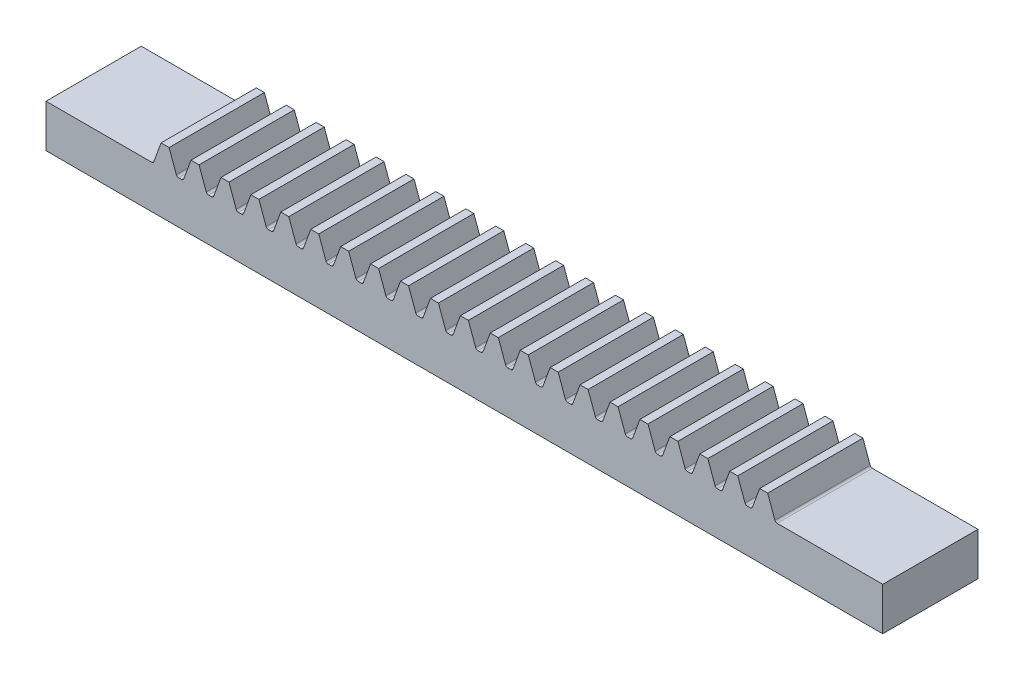
from build123d import *

# Parameters (mm, degrees)
SKETCH1_W              = 155.663706144
SKETCH1_H              = 4
BOSS_EXTRUDE1_DEPTH    = 10
BOSS_EXTRUDE4_DEPTH    = 10
FILLET1_R              = 0.5
LPATTERN1_COUNT        = 21
LPATTERN1_PITCH        = 6.283185307
FILLET1_OF_LPATTERN1_R = 0.5
BOSS_EXTRUDE6_DEPTH    = 6
SKETCH11_W             = 16
SKETCH11_H             = 4
BOSS_EXTRUDE8_DEPTH    = 10
SKETCH12_W             = 16
SKETCH12_H             = 4
BOSS_EXTRUDE9_DEPTH    = 10
SKETCH15_W             = 175.663706144
SKETCH15_H             = 16
BOSS_EXTRUDE10_DEPTH   = 5
BOSS_EXTRUDE11_DEPTH   = 4


with BuildPart() as part:
    # Sketch1 → Boss-Extrude1 (new body)
    with BuildSketch(Plane.XY):
        with Locations((0, 2)):
            Rectangle(SKETCH1_W, SKETCH1_H)
    extrude(amount=BOSS_EXTRUDE1_DEPTH)

    # Sketch2 → Boss-Extrude4 (add)
    with BuildSketch(Plane.XY):
        Polygon((-65.312574984, 4), (-63.67470893, 8.5), (-61.988997214, 8.5), (-60.351131159, 4), align=None)
    boss_extrude4 = extrude(amount=BOSS_EXTRUDE4_DEPTH)

    # Fillet1
    fillet1_edges = [part.edges().sort_by_distance(p)[0] for p in [
        (-60.351131159, 4, 5),
        (-65.312574984, 4, 5),
    ]]
    fillet(fillet1_edges, radius=FILLET1_R)

    # LPattern1: Boss-Extrude4 ×21
    with Locations(*[(i * LPATTERN1_PITCH, 0, 0) for i in range(1, LPATTERN1_COUNT)]):
        add(boss_extrude4)

    # Fillet1 of LPattern1
    fillet1_of_lpattern1_edges = [part.edges().sort_by_distance(p)[0] for p in [
        (-54.067945852, 4, 5),
        (-59.029389677, 4, 5),
        (-47.784760545, 4, 5),
        (-52.74620437, 4, 5),
        (-41.501575238, 4, 5),
        (-46.463019063, 4, 5),
        (-35.218389931, 4, 5),
        (-40.179833756, 4, 5),
        (-28.935204623, 4, 5),
        (-33.896648448, 4, 5),
        (-22.652019316, 4, 5),
        (-27.613463141, 4, 5),
        (-16.368834009, 4, 5),
        (-21.330277834, 4, 5),
        (-10.085648702, 4, 5),
        (-15.047092527, 4, 5),
        (-3.802463395, 4, 5),
        (-8.76390722, 4, 5),
        (2.480721912, 4, 5),
        (-2.480721912, 4, 5),
        (8.76390722, 4, 5),
        (3.802463395, 4, 5),
        (15.047092527, 4, 5),
        (10.085648702, 4, 5),
        (21.330277834, 4, 5),
        (16.368834009, 4, 5),
        (27.613463141, 4, 5),
        (22.652019316, 4, 5),
        (33.896648448, 4, 5),
        (28.935204623, 4, 5),
        (40.179833756, 4, 5),
        (35.218389931, 4, 5),
        (46.463019063, 4, 5),
        (41.501575238, 4, 5),
        (52.74620437, 4, 5),
        (47.784760545, 4, 5),
        (59.029389677, 4, 5),
        (54.067945852, 4, 5),
        (65.312574984, 4, 5),
        (60.351131159, 4, 5),
    ]]
    fillet(fillet1_of_lpattern1_edges, radius=FILLET1_OF_LPATTERN1_R)

    # Sketch9 → Boss-Extrude6 (add)
    with BuildSketch(Plane.XY.offset(10)):
        with BuildLine():
            Line((-77.831853072, 4), (-77.831853072, 0))
            Line((-77.831853072, 0), (77.831853072, 0))
            Line((77.831853072, 0), (77.831853072, 4))
            Line((77.831853072, 4), (65.662678753, 4))
            ThreePointArc((65.662678753, 4), (65.375890535, 4.090423978), (65.192832443, 4.328989928))
            Line((65.192832443, 4.328989928), (63.67470893, 8.5))
            Line((63.67470893, 8.5), (61.988997214, 8.5))
            Line((61.988997214, 8.5), (60.470873701, 4.328989928))
            ThreePointArc((60.470873701, 4.328989928), (60.287815608, 4.090423978), (60.00102739, 4))
            Line((60.00102739, 4), (59.379493446, 4))
            ThreePointArc((59.379493446, 4), (59.092705228, 4.090423978), (58.909647136, 4.328989928))
            Line((58.909647136, 4.328989928), (57.391523623, 8.5))
            Line((57.391523623, 8.5), (55.705811906, 8.5))
            Line((55.705811906, 8.5), (54.187688393, 4.328989928))
            ThreePointArc((54.187688393, 4.328989928), (54.004630301, 4.090423978), (53.717842083, 4))
            Line((53.717842083, 4), (53.096308139, 4))
            ThreePointArc((53.096308139, 4), (52.809519921, 4.090423978), (52.626461829, 4.328989928))
            Line((52.626461829, 4.328989928), (51.108338316, 8.5))
            Line((51.108338316, 8.5), (49.422626599, 8.5))
            Line((49.422626599, 8.5), (47.904503086, 4.328989928))
            ThreePointArc((47.904503086, 4.328989928), (47.721444994, 4.090423978), (47.434656776, 4))
            Line((47.434656776, 4), (46.813122832, 4))
            ThreePointArc((46.813122832, 4), (46.526334614, 4.090423978), (46.343276521, 4.328989928))
            Line((46.343276521, 4.328989928), (44.825153009, 8.5))
            Line((44.825153009, 8.5), (43.139441292, 8.5))
            Line((43.139441292, 8.5), (41.621317779, 4.328989928))
            ThreePointArc((41.621317779, 4.328989928), (41.438259687, 4.090423978), (41.151471469, 4))
            Line((41.151471469, 4), (40.529937525, 4))
            ThreePointArc((40.529937525, 4), (40.243149306, 4.090423978), (40.060091214, 4.328989928))
            Line((40.060091214, 4.328989928), (38.541967701, 8.5))
            Line((38.541967701, 8.5), (36.856255985, 8.5))
            Line((36.856255985, 8.5), (35.338132472, 4.328989928))
            ThreePointArc((35.338132472, 4.328989928), (35.15507438, 4.090423978), (34.868286162, 4))
            Line((34.868286162, 4), (34.246752217, 4))
            ThreePointArc((34.246752217, 4), (33.959963999, 4.090423978), (33.776905907, 4.328989928))
            Line((33.776905907, 4.328989928), (32.258782394, 8.5))
            Line((32.258782394, 8.5), (30.573070678, 8.5))
            Line((30.573070678, 8.5), (29.054947165, 4.328989928))
            ThreePointArc((29.054947165, 4.328989928), (28.871889073, 4.090423978), (28.585100854, 4))
            Line((28.585100854, 4), (27.96356691, 4))
            ThreePointArc((27.96356691, 4), (27.676778692, 4.090423978), (27.4937206, 4.328989928))
            Line((27.4937206, 4.328989928), (25.975597087, 8.5))
            Line((25.975597087, 8.5), (24.28988537, 8.5))
            Line((24.28988537, 8.5), (22.771761858, 4.328989928))
            ThreePointArc((22.771761858, 4.328989928), (22.588703765, 4.090423978), (22.301915547, 4))
            Line((22.301915547, 4), (21.680381603, 4))
            ThreePointArc((21.680381603, 4), (21.393593385, 4.090423978), (21.210535293, 4.328989928))
            Line((21.210535293, 4.328989928), (19.69241178, 8.5))
            Line((19.69241178, 8.5), (18.006700063, 8.5))
            Line((18.006700063, 8.5), (16.48857655, 4.328989928))
            ThreePointArc((16.48857655, 4.328989928), (16.305518458, 4.090423978), (16.01873024, 4))
            Line((16.01873024, 4), (15.397196296, 4))
            ThreePointArc((15.397196296, 4), (15.110408078, 4.090423978), (14.927349986, 4.328989928))
            Line((14.927349986, 4.328989928), (13.409226473, 8.5))
            Line((13.409226473, 8.5), (11.723514756, 8.5))
            Line((11.723514756, 8.5), (10.205391243, 4.328989928))
            ThreePointArc((10.205391243, 4.328989928), (10.022333151, 4.090423978), (9.735544933, 4))
            Line((9.735544933, 4), (9.114010989, 4))
            ThreePointArc((9.114010989, 4), (8.827222771, 4.090423978), (8.644164678, 4.328989928))
            Line((8.644164678, 4.328989928), (7.126041165, 8.5))
            Line((7.126041165, 8.5), (5.440329449, 8.5))
            Line((5.440329449, 8.5), (3.922205936, 4.328989928))
            ThreePointArc((3.922205936, 4.328989928), (3.739147844, 4.090423978), (3.452359626, 4))
            Line((3.452359626, 4), (2.830825682, 4))
            ThreePointArc((2.830825682, 4), (2.544037463, 4.090423978), (2.360979371, 4.328989928))
            Line((2.360979371, 4.328989928), (0.842855858, 8.5))
            Line((0.842855858, 8.5), (-0.842855858, 8.5))
            Line((-0.842855858, 8.5), (-2.360979371, 4.328989928))
            ThreePointArc((-2.360979371, 4.328989928), (-2.544037463, 4.090423978), (-2.830825682, 4))
            Line((-2.830825682, 4), (-3.452359626, 4))
            ThreePointArc((-3.452359626, 4), (-3.739147844, 4.090423978), (-3.922205936, 4.328989928))
            Line((-3.922205936, 4.328989928), (-5.440329449, 8.5))
            Line((-5.440329449, 8.5), (-7.126041165, 8.5))
            Line((-7.126041165, 8.5), (-8.644164678, 4.328989928))
            ThreePointArc((-8.644164678, 4.328989928), (-8.827222771, 4.090423978), (-9.114010989, 4))
            Line((-9.114010989, 4), (-9.735544933, 4))
            ThreePointArc((-9.735544933, 4), (-10.022333151, 4.090423978), (-10.205391243, 4.328989928))
            Line((-10.205391243, 4.328989928), (-11.723514756, 8.5))
            Line((-11.723514756, 8.5), (-13.409226473, 8.5))
            Line((-13.409226473, 8.5), (-14.927349986, 4.328989928))
            ThreePointArc((-14.927349986, 4.328989928), (-15.110408078, 4.090423978), (-15.397196296, 4))
            Line((-15.397196296, 4), (-16.01873024, 4))
            ThreePointArc((-16.01873024, 4), (-16.305518458, 4.090423978), (-16.48857655, 4.328989928))
            Line((-16.48857655, 4.328989928), (-18.006700063, 8.5))
            Line((-18.006700063, 8.5), (-19.69241178, 8.5))
            Line((-19.69241178, 8.5), (-21.210535293, 4.328989928))
            ThreePointArc((-21.210535293, 4.328989928), (-21.393593385, 4.090423978), (-21.680381603, 4))
            Line((-21.680381603, 4), (-22.301915547, 4))
            ThreePointArc((-22.301915547, 4), (-22.588703765, 4.090423978), (-22.771761858, 4.328989928))
            Line((-22.771761858, 4.328989928), (-24.28988537, 8.5))
            Line((-24.28988537, 8.5), (-25.975597087, 8.5))
            Line((-25.975597087, 8.5), (-27.4937206, 4.328989928))
            ThreePointArc((-27.4937206, 4.328989928), (-27.676778692, 4.090423978), (-27.96356691, 4))
            Line((-27.96356691, 4), (-28.585100854, 4))
            ThreePointArc((-28.585100854, 4), (-28.871889073, 4.090423978), (-29.054947165, 4.328989928))
            Line((-29.054947165, 4.328989928), (-30.573070678, 8.5))
            Line((-30.573070678, 8.5), (-32.258782394, 8.5))
            Line((-32.258782394, 8.5), (-33.776905907, 4.328989928))
            ThreePointArc((-33.776905907, 4.328989928), (-33.959963999, 4.090423978), (-34.246752217, 4))
            Line((-34.246752217, 4), (-34.868286162, 4))
            ThreePointArc((-34.868286162, 4), (-35.15507438, 4.090423978), (-35.338132472, 4.328989928))
            Line((-35.338132472, 4.328989928), (-36.856255985, 8.5))
            Line((-36.856255985, 8.5), (-38.541967701, 8.5))
            Line((-38.541967701, 8.5), (-40.060091214, 4.328989928))
            ThreePointArc((-40.060091214, 4.328989928), (-40.243149306, 4.090423978), (-40.529937525, 4))
            Line((-40.529937525, 4), (-41.151471469, 4))
            ThreePointArc((-41.151471469, 4), (-41.438259687, 4.090423978), (-41.621317779, 4.328989928))
            Line((-41.621317779, 4.328989928), (-43.139441292, 8.5))
            Line((-43.139441292, 8.5), (-44.825153009, 8.5))
            Line((-44.825153009, 8.5), (-46.343276521, 4.328989928))
            ThreePointArc((-46.343276521, 4.328989928), (-46.526334614, 4.090423978), (-46.813122832, 4))
            Line((-46.813122832, 4), (-47.434656776, 4))
            ThreePointArc((-47.434656776, 4), (-47.721444994, 4.090423978), (-47.904503086, 4.328989928))
            Line((-47.904503086, 4.328989928), (-49.422626599, 8.5))
            Line((-49.422626599, 8.5), (-51.108338316, 8.5))
            Line((-51.108338316, 8.5), (-52.626461829, 4.328989928))
            ThreePointArc((-52.626461829, 4.328989928), (-52.809519921, 4.090423978), (-53.096308139, 4))
            Line((-53.096308139, 4), (-53.717842083, 4))
            ThreePointArc((-53.717842083, 4), (-54.004630301, 4.090423978), (-54.187688393, 4.328989928))
            Line((-54.187688393, 4.328989928), (-55.705811906, 8.5))
            Line((-55.705811906, 8.5), (-57.391523623, 8.5))
            Line((-57.391523623, 8.5), (-58.909647136, 4.328989928))
            ThreePointArc((-58.909647136, 4.328989928), (-59.092705228, 4.090423978), (-59.379493446, 4))
            Line((-59.379493446, 4), (-60.00102739, 4))
            ThreePointArc((-60.00102739, 4), (-60.287815608, 4.090423978), (-60.470873701, 4.328989928))
            Line((-60.470873701, 4.328989928), (-61.988997214, 8.5))
            Line((-61.988997214, 8.5), (-63.67470893, 8.5))
            Line((-63.67470893, 8.5), (-65.192832443, 4.328989928))
            ThreePointArc((-65.192832443, 4.328989928), (-65.375890535, 4.090423978), (-65.662678753, 4))
            Line((-65.662678753, 4), (-77.831853072, 4))
        make_face()
    extrude(amount=BOSS_EXTRUDE6_DEPTH)

    # Sketch11 → Boss-Extrude8 (add)
    with BuildSketch(Plane.ZY.offset(77.831853072)):
        with Locations((8, 2)):
            Rectangle(SKETCH11_W, SKETCH11_H)
    extrude(amount=BOSS_EXTRUDE8_DEPTH)

    # Sketch12 → Boss-Extrude9 (add)
    with BuildSketch(Plane(origin=(77.831853072, 0, 0), x_dir=(0, 0, -1), z_dir=(1, 0, 0))):
        with Locations((-8, 2)):
            Rectangle(SKETCH12_W, SKETCH12_H)
    extrude(amount=BOSS_EXTRUDE9_DEPTH)

    # Sketch15 → Boss-Extrude10 (add)
    with BuildSketch(Plane.XZ):
        with Locations((0, 8)):
            Rectangle(SKETCH15_W, SKETCH15_H)
    extrude(amount=BOSS_EXTRUDE10_DEPTH)

    # Sketch16 → Boss-Extrude11 (add)
    with BuildSketch(Plane.XY.offset(16)):
        with BuildLine():
            Line((-61.988997214, 8.5), (-63.67470893, 8.5))
            Line((-63.67470893, 8.5), (-65.192832443, 4.328989928))
            ThreePointArc((-65.192832443, 4.328989928), (-65.375890535, 4.090423978), (-65.662678753, 4))
            Line((-65.662678753, 4), (-87.831853072, 4))
            Line((-87.831853072, 4), (-87.831853072, -5))
            Line((-87.831853072, -5), (87.831853072, -5))
            Line((87.831853072, -5), (87.831853072, 4))
            Line((87.831853072, 4), (65.662678753, 4))
            ThreePointArc((65.662678753, 4), (65.375890535, 4.090423978), (65.192832443, 4.328989928))
            Line((65.192832443, 4.328989928), (63.67470893, 8.5))
            Line((63.67470893, 8.5), (61.988997214, 8.5))
            Line((61.988997214, 8.5), (60.470873701, 4.328989928))
            ThreePointArc((60.470873701, 4.328989928), (60.287815608, 4.090423978), (60.00102739, 4))
            Line((60.00102739, 4), (59.379493446, 4))
            ThreePointArc((59.379493446, 4), (59.092705228, 4.090423978), (58.909647136, 4.328989928))
            Line((58.909647136, 4.328989928), (57.391523623, 8.5))
            Line((57.391523623, 8.5), (55.705811906, 8.5))
            Line((55.705811906, 8.5), (54.187688393, 4.328989928))
            ThreePointArc((54.187688393, 4.328989928), (54.004630301, 4.090423978), (53.717842083, 4))
            Line((53.717842083, 4), (53.096308139, 4))
            ThreePointArc((53.096308139, 4), (52.809519921, 4.090423978), (52.626461829, 4.328989928))
            Line((52.626461829, 4.328989928), (51.108338316, 8.5))
            Line((51.108338316, 8.5), (49.422626599, 8.5))
            Line((49.422626599, 8.5), (47.904503086, 4.328989928))
            ThreePointArc((47.904503086, 4.328989928), (47.721444994, 4.090423978), (47.434656776, 4))
            Line((47.434656776, 4), (46.813122832, 4))
            ThreePointArc((46.813122832, 4), (46.526334614, 4.090423978), (46.343276521, 4.328989928))
            Line((46.343276521, 4.328989928), (44.825153009, 8.5))
            Line((44.825153009, 8.5), (43.139441292, 8.5))
            Line((43.139441292, 8.5), (41.621317779, 4.328989928))
            ThreePointArc((41.621317779, 4.328989928), (41.438259687, 4.090423978), (41.151471469, 4))
            Line((41.151471469, 4), (40.529937525, 4))
            ThreePointArc((40.529937525, 4), (40.243149306, 4.090423978), (40.060091214, 4.328989928))
            Line((40.060091214, 4.328989928), (38.541967701, 8.5))
            Line((38.541967701, 8.5), (36.856255985, 8.5))
            Line((36.856255985, 8.5), (35.338132472, 4.328989928))
            ThreePointArc((35.338132472, 4.328989928), (35.15507438, 4.090423978), (34.868286162, 4))
            Line((34.868286162, 4), (34.246752217, 4))
            ThreePointArc((34.246752217, 4), (33.959963999, 4.090423978), (33.776905907, 4.328989928))
            Line((33.776905907, 4.328989928), (32.258782394, 8.5))
            Line((32.258782394, 8.5), (30.573070678, 8.5))
            Line((30.573070678, 8.5), (29.054947165, 4.328989928))
            ThreePointArc((29.054947165, 4.328989928), (28.871889073, 4.090423978), (28.585100854, 4))
            Line((28.585100854, 4), (27.96356691, 4))
            ThreePointArc((27.96356691, 4), (27.676778692, 4.090423978), (27.4937206, 4.328989928))
            Line((27.4937206, 4.328989928), (25.975597087, 8.5))
            Line((25.975597087, 8.5), (24.28988537, 8.5))
            Line((24.28988537, 8.5), (22.771761858, 4.328989928))
            ThreePointArc((22.771761858, 4.328989928), (22.588703765, 4.090423978), (22.301915547, 4))
            Line((22.301915547, 4), (21.680381603, 4))
            ThreePointArc((21.680381603, 4), (21.393593385, 4.090423978), (21.210535293, 4.328989928))
            Line((21.210535293, 4.328989928), (19.69241178, 8.5))
            Line((19.69241178, 8.5), (18.006700063, 8.5))
            Line((18.006700063, 8.5), (16.48857655, 4.328989928))
            ThreePointArc((16.48857655, 4.328989928), (16.305518458, 4.090423978), (16.01873024, 4))
            Line((16.01873024, 4), (15.397196296, 4))
            ThreePointArc((15.397196296, 4), (15.110408078, 4.090423978), (14.927349986, 4.328989928))
            Line((14.927349986, 4.328989928), (13.409226473, 8.5))
            Line((13.409226473, 8.5), (11.723514756, 8.5))
            Line((11.723514756, 8.5), (10.205391243, 4.328989928))
            ThreePointArc((10.205391243, 4.328989928), (10.022333151, 4.090423978), (9.735544933, 4))
            Line((9.735544933, 4), (9.114010989, 4))
            ThreePointArc((9.114010989, 4), (8.827222771, 4.090423978), (8.644164678, 4.328989928))
            Line((8.644164678, 4.328989928), (7.126041165, 8.5))
            Line((7.126041165, 8.5), (5.440329449, 8.5))
            Line((5.440329449, 8.5), (3.922205936, 4.328989928))
            ThreePointArc((3.922205936, 4.328989928), (3.739147844, 4.090423978), (3.452359626, 4))
            Line((3.452359626, 4), (2.830825682, 4))
            ThreePointArc((2.830825682, 4), (2.544037463, 4.090423978), (2.360979371, 4.328989928))
            Line((2.360979371, 4.328989928), (0.842855858, 8.5))
            Line((0.842855858, 8.5), (-0.842855858, 8.5))
            Line((-0.842855858, 8.5), (-2.360979371, 4.328989928))
            ThreePointArc((-2.360979371, 4.328989928), (-2.544037463, 4.090423978), (-2.830825682, 4))
            Line((-2.830825682, 4), (-3.452359626, 4))
            ThreePointArc((-3.452359626, 4), (-3.739147844, 4.090423978), (-3.922205936, 4.328989928))
            Line((-3.922205936, 4.328989928), (-5.440329449, 8.5))
            Line((-5.440329449, 8.5), (-7.126041165, 8.5))
            Line((-7.126041165, 8.5), (-8.644164678, 4.328989928))
            ThreePointArc((-8.644164678, 4.328989928), (-8.827222771, 4.090423978), (-9.114010989, 4))
            Line((-9.114010989, 4), (-9.735544933, 4))
            ThreePointArc((-9.735544933, 4), (-10.022333151, 4.090423978), (-10.205391243, 4.328989928))
            Line((-10.205391243, 4.328989928), (-11.723514756, 8.5))
            Line((-11.723514756, 8.5), (-13.409226473, 8.5))
            Line((-13.409226473, 8.5), (-14.927349986, 4.328989928))
            ThreePointArc((-14.927349986, 4.328989928), (-15.110408078, 4.090423978), (-15.397196296, 4))
            Line((-15.397196296, 4), (-16.01873024, 4))
            ThreePointArc((-16.01873024, 4), (-16.305518458, 4.090423978), (-16.48857655, 4.328989928))
            Line((-16.48857655, 4.328989928), (-18.006700063, 8.5))
            Line((-18.006700063, 8.5), (-19.69241178, 8.5))
            Line((-19.69241178, 8.5), (-21.210535293, 4.328989928))
            ThreePointArc((-21.210535293, 4.328989928), (-21.393593385, 4.090423978), (-21.680381603, 4))
            Line((-21.680381603, 4), (-22.301915547, 4))
            ThreePointArc((-22.301915547, 4), (-22.588703765, 4.090423978), (-22.771761858, 4.328989928))
            Line((-22.771761858, 4.328989928), (-24.28988537, 8.5))
            Line((-24.28988537, 8.5), (-25.975597087, 8.5))
            Line((-25.975597087, 8.5), (-27.4937206, 4.328989928))
            ThreePointArc((-27.4937206, 4.328989928), (-27.676778692, 4.090423978), (-27.96356691, 4))
            Line((-27.96356691, 4), (-28.585100854, 4))
            ThreePointArc((-28.585100854, 4), (-28.871889073, 4.090423978), (-29.054947165, 4.328989928))
            Line((-29.054947165, 4.328989928), (-30.573070678, 8.5))
            Line((-30.573070678, 8.5), (-32.258782394, 8.5))
            Line((-32.258782394, 8.5), (-33.776905907, 4.328989928))
            ThreePointArc((-33.776905907, 4.328989928), (-33.959963999, 4.090423978), (-34.246752217, 4))
            Line((-34.246752217, 4), (-34.868286162, 4))
            ThreePointArc((-34.868286162, 4), (-35.15507438, 4.090423978), (-35.338132472, 4.328989928))
            Line((-35.338132472, 4.328989928), (-36.856255985, 8.5))
            Line((-36.856255985, 8.5), (-38.541967701, 8.5))
            Line((-38.541967701, 8.5), (-40.060091214, 4.328989928))
            ThreePointArc((-40.060091214, 4.328989928), (-40.243149306, 4.090423978), (-40.529937525, 4))
            Line((-40.529937525, 4), (-41.151471469, 4))
            ThreePointArc((-41.151471469, 4), (-41.438259687, 4.090423978), (-41.621317779, 4.328989928))
            Line((-41.621317779, 4.328989928), (-43.139441292, 8.5))
            Line((-43.139441292, 8.5), (-44.825153009, 8.5))
            Line((-44.825153009, 8.5), (-46.343276521, 4.328989928))
            ThreePointArc((-46.343276521, 4.328989928), (-46.526334614, 4.090423978), (-46.813122832, 4))
            Line((-46.813122832, 4), (-47.434656776, 4))
            ThreePointArc((-47.434656776, 4), (-47.721444994, 4.090423978), (-47.904503086, 4.328989928))
            Line((-47.904503086, 4.328989928), (-49.422626599, 8.5))
            Line((-49.422626599, 8.5), (-51.108338316, 8.5))
            Line((-51.108338316, 8.5), (-52.626461829, 4.328989928))
            ThreePointArc((-52.626461829, 4.328989928), (-52.809519921, 4.090423978), (-53.096308139, 4))
            Line((-53.096308139, 4), (-53.717842083, 4))
            ThreePointArc((-53.717842083, 4), (-54.004630301, 4.090423978), (-54.187688393, 4.328989928))
            Line((-54.187688393, 4.328989928), (-55.705811906, 8.5))
            Line((-55.705811906, 8.5), (-57.391523623, 8.5))
            Line((-57.391523623, 8.5), (-58.909647136, 4.328989928))
            ThreePointArc((-58.909647136, 4.328989928), (-59.092705228, 4.090423978), (-59.379493446, 4))
            Line((-59.379493446, 4), (-60.00102739, 4))
            ThreePointArc((-60.00102739, 4), (-60.287815608, 4.090423978), (-60.470873701, 4.328989928))
            Line((-60.470873701, 4.328989928), (-61.988997214, 8.5))
        make_face()
    extrude(amount=BOSS_EXTRUDE11_DEPTH)


solid = part.part
